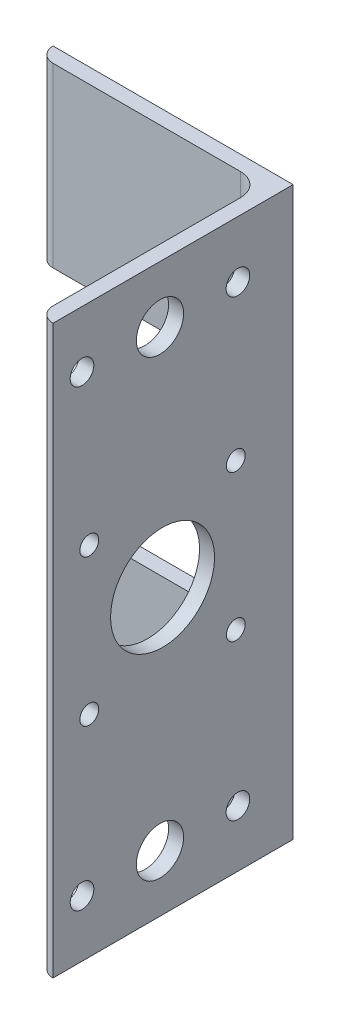
from build123d import *

# Parameters (mm, degrees)
HIERRO_ANGULAR_2_X_2_X_0_125_1_DEPTH = 120
CROQUIS3_W                           = 47.625
CROQUIS3_H                           = 45
CORTAR_EXTRUIR1_DEPTH                = 10
CROQUIS4_R                           = 5
CROQUIS4_R_2                         = 2.5
CORTAR_EXTRUIR2_DEPTH                = 10
CROQUIS5_R                           = 2
CROQUIS5_R_2                         = 11
CORTAR_EXTRUIR3_DEPTH                = 3.175


with BuildPart() as part:
    # Sketch1 → Hierro angular 2 X 2 X 0.125(1) (new body)
    with BuildSketch(Plane(origin=(0, 0, 0), x_dir=(-1, 0, 0), z_dir=(0, 1, 0))):
        with BuildLine():
            Line((0, 0), (0, 50.8))
            Line((0, 50.8), (0.00508, 50.8))
            ThreePointArc((0.00508, 50.8), (2.246551928, 49.871551928), (3.175, 47.63008))
            Line((3.175, 47.63008), (3.175, 7.9375))
            ThreePointArc((3.175, 7.9375), (4.569903955, 4.569903955), (7.9375, 3.175))
            Line((7.9375, 3.175), (47.63008, 3.175))
            ThreePointArc((47.63008, 3.175), (49.871551928, 2.246551928), (50.8, 0.00508))
            Line((50.8, 0.00508), (50.8, 0))
            Line((50.8, 0), (0, 0))
        make_face()
    extrude(amount=HIERRO_ANGULAR_2_X_2_X_0_125_1_DEPTH)

    # Croquis3 → Cortar-Extruir1 (cut)
    with BuildSketch(Plane(origin=(0, 0, 0), x_dir=(-1, 0, 0), z_dir=(0, 0, -1))):
        with Locations((26.9875, 60)):
            Rectangle(CROQUIS3_W, CROQUIS3_H)
    extrude(amount=-CORTAR_EXTRUIR1_DEPTH, mode=Mode.SUBTRACT)

    # Croquis4 → Cortar-Extruir2 (cut)
    with BuildSketch(Plane.ZY.offset(3.175)):
        with Locations((28.175, 12)):
            Circle(CROQUIS4_R)
        with Locations((11.675, 12)):
            Circle(CROQUIS4_R_2)
        with Locations((44.675, 12)):
            Circle(CROQUIS4_R_2)
        with Locations((44.675, 108)):
            Circle(CROQUIS4_R_2)
        with Locations((28.175, 108)):
            Circle(CROQUIS4_R)
        with Locations((11.675, 108)):
            Circle(CROQUIS4_R_2)
    extrude(amount=-CORTAR_EXTRUIR2_DEPTH, mode=Mode.SUBTRACT)

    # Croquis5 → Cortar-Extruir3 (cut)
    with BuildSketch(Plane.ZY.offset(3.175)):
        with Locations((43.13008, 75.5)):
            Circle(CROQUIS5_R)
        with Locations((43.13008, 44.5)):
            Circle(CROQUIS5_R)
        with Locations((12.13008, 44.5)):
            Circle(CROQUIS5_R)
        with Locations((12.13008, 75.5)):
            Circle(CROQUIS5_R)
        with Locations((27.63008, 60)):
            Circle(CROQUIS5_R_2)
    extrude(amount=-CORTAR_EXTRUIR3_DEPTH, mode=Mode.SUBTRACT)


solid = part.part
